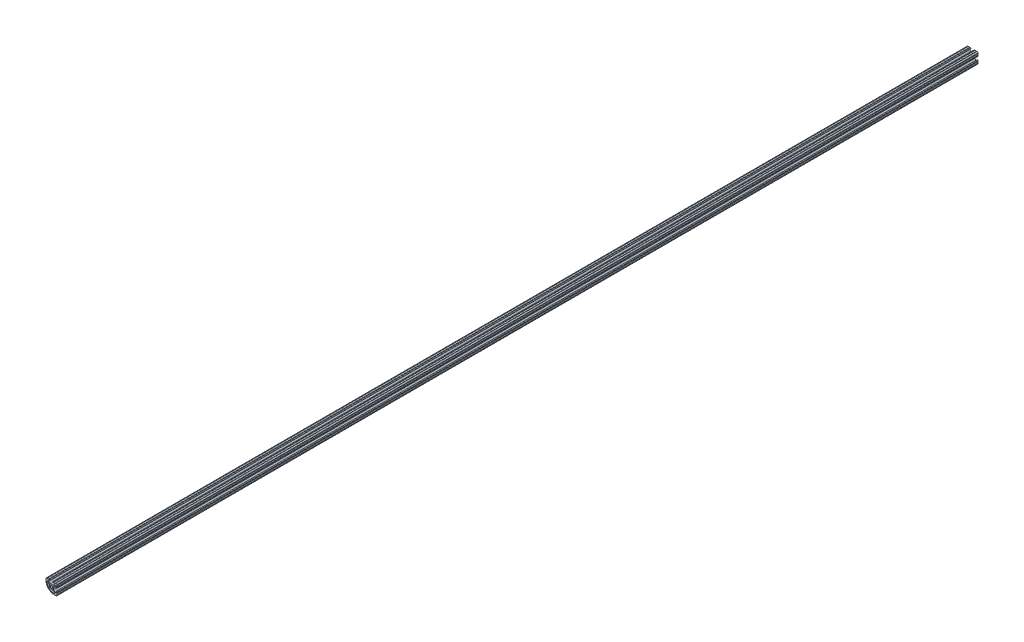
from build123d import *

# Parameters (mm, degrees)
BOSS_EXTRUDE1_DEPTH = 1250
SKETCH4_R           = 22.750036828
CUT_EXTRUDE1_DEPTH  = 361.95


with BuildPart() as part:
    # Sketch3 → Boss-Extrude1 (new, symmetric)
    with BuildSketch(Plane.XY):
        with BuildLine():
            Line((6.350000091, 12.7), (9.5758, 12.7))
            ThreePointArc((9.5758, 12.7), (10.0838, 12.192), (10.5918, 12.7))
            ThreePointArc((10.5918, 12.7), (11.398573212, 12.53952283), (12.082522516, 12.082522516))
            Line((12.082522516, 12.082522516), (1.841111635, 1.841111635))
            ThreePointArc((1.841111635, 1.841111635), (-1.841111635, 1.841111635), (-1.841111635, -1.841111635))
            Line((-1.841111635, -1.841111635), (-3.170518398, -3.170518398))
            ThreePointArc((-3.170518398, -3.170518398), (-4.284365606, -1.322340795), (-4.405901938, 0.832106923))
            ThreePointArc((-4.405901938, 0.832106923), (-4.49196258, 2.357684911), (-5.280684798, 3.666391103))
            Line((-5.280684798, 3.666391103), (-8.603375093, 6.989081397))
            ThreePointArc((-8.603375093, 6.989081397), (-9.812092525, 7.226672612), (-10.489512256, 6.197814058))
            ThreePointArc((-10.489512256, 6.197814058), (-9.179037358, -0.164701156), (-5.55781952, -5.55781952))
            Line((-5.55781952, -5.55781952), (-7.120384159, -7.120384159))
            ThreePointArc((-7.120384159, -7.120384159), (-8.636327096, -5.410633429), (-9.936651338, -3.531674301))
            ThreePointArc((-9.936651338, -3.531674301), (-9.753165795, -2.842051688), (-10.440280632, -2.649387487))
            ThreePointArc((-10.440280632, -2.649387487), (-11.049200851, -1.406952263), (-11.566334617, -0.123596589))
            ThreePointArc((-11.566334617, -0.123596589), (-11.250376175, 0.51626008), (-11.885963187, 0.840721857))
            ThreePointArc((-11.885963187, 0.840721857), (-12.495391993, 3.565453333), (-12.7, 6.350000091))
            Line((-12.7, 6.350000091), (-12.7, 9.5758))
            ThreePointArc((-12.7, 9.5758), (-12.192, 10.0838), (-12.7, 10.5918))
            ThreePointArc((-12.7, 10.5918), (-12.082522516, 12.082522516), (-10.5918, 12.7))
            ThreePointArc((-10.5918, 12.7), (-10.0838, 12.192), (-9.5758, 12.7))
            Line((-9.5758, 12.7), (-6.350000091, 12.7))
            ThreePointArc((-6.350000091, 12.7), (-5.842000091, 12.192), (-5.334000091, 12.7))
            Line((-5.334000091, 12.7), (-4.3561, 12.7))
            ThreePointArc((-4.3561, 12.7), (-3.2512, 11.5951), (-4.3561, 10.4902))
            Line((-4.3561, 10.4902), (-6.3119, 10.4902))
            ThreePointArc((-6.3119, 10.4902), (-7.332694495, 9.808126924), (-7.093182283, 8.604017717))
            Line((-7.093182283, 8.604017717), (-3.914900535, 5.42573597))
            ThreePointArc((-3.914900535, 5.42573597), (-2.884856402, 4.737482484), (-1.669836505, 4.4958))
            Line((-1.669836505, 4.4958), (1.669836505, 4.4958))
            ThreePointArc((1.669836505, 4.4958), (2.884856402, 4.737482484), (3.914900535, 5.42573597))
            Line((3.914900535, 5.42573597), (7.093182283, 8.604017717))
            ThreePointArc((7.093182283, 8.604017717), (7.332694495, 9.808126924), (6.3119, 10.4902))
            Line((6.3119, 10.4902), (4.3561, 10.4902))
            ThreePointArc((4.3561, 10.4902), (3.2512, 11.5951), (4.3561, 12.7))
            Line((4.3561, 12.7), (5.334000091, 12.7))
            ThreePointArc((5.334000091, 12.7), (5.842000091, 12.192), (6.350000091, 12.7))
        make_face()
    extrude(amount=BOSS_EXTRUDE1_DEPTH, both=True)

    # Mirror1: part across plane


with BuildPart() as part_1:
    add(part.part)
    add(part.part.mirror(Plane(origin=(1.841111635, 1.841111635, 1250), x_dir=(0, 0, 1), z_dir=(-0.707106781186552, 0.707106781186543, 0))))

    # Sketch4 → Cut-Extrude1 (cut)
    with BuildSketch(Plane.XY.offset(1250)):
        Circle(SKETCH4_R)
    extrude(amount=-CUT_EXTRUDE1_DEPTH, mode=Mode.SUBTRACT)


solid = part_1.part
